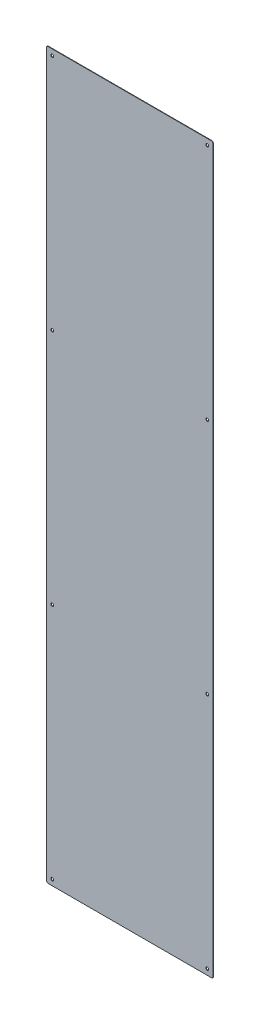
from build123d import *

# Parameters (mm, degrees)
SKETCH1_W           = 370
SKETCH1_H           = 1613
BOSS_EXTRUDE1_DEPTH = 1
SKETCH2_R           = 3.25
CUT_EXTRUDE1_DEPTH  = 1
LPATTERN1_COUNT     = 4
LPATTERN1_PITCH     = 529
FILLET1_R           = 3


with BuildPart() as part:
    # Sketch1 → Boss-Extrude1 (new body)
    with BuildSketch(Plane.XY):
        Rectangle(SKETCH1_W, SKETCH1_H)
    extrude(amount=BOSS_EXTRUDE1_DEPTH)

    # Sketch2 → Cut-Extrude1 (cut)
    with BuildSketch(Plane.XY.offset(1)):
        with Locations((-172.5, -793.5)):
            Circle(SKETCH2_R)
        with Locations((172.5, -793.5)):
            Circle(SKETCH2_R)
    cut_extrude1 = extrude(amount=-CUT_EXTRUDE1_DEPTH, mode=Mode.SUBTRACT)

    # LPattern1: Cut-Extrude1 ×4
    with Locations(*[(0, i * LPATTERN1_PITCH, 0) for i in range(1, LPATTERN1_COUNT)]):
        add(cut_extrude1, mode=Mode.SUBTRACT)

    # Fillet1
    fillet1_edges = [part.edges().sort_by_distance(p)[0] for p in [
        (185, -806.5, 0.5),
        (-185, -806.5, 0.5),
        (-185, 806.5, 0.5),
        (185, 806.5, 0.5),
    ]]
    fillet(fillet1_edges, radius=FILLET1_R)


solid = part.part
